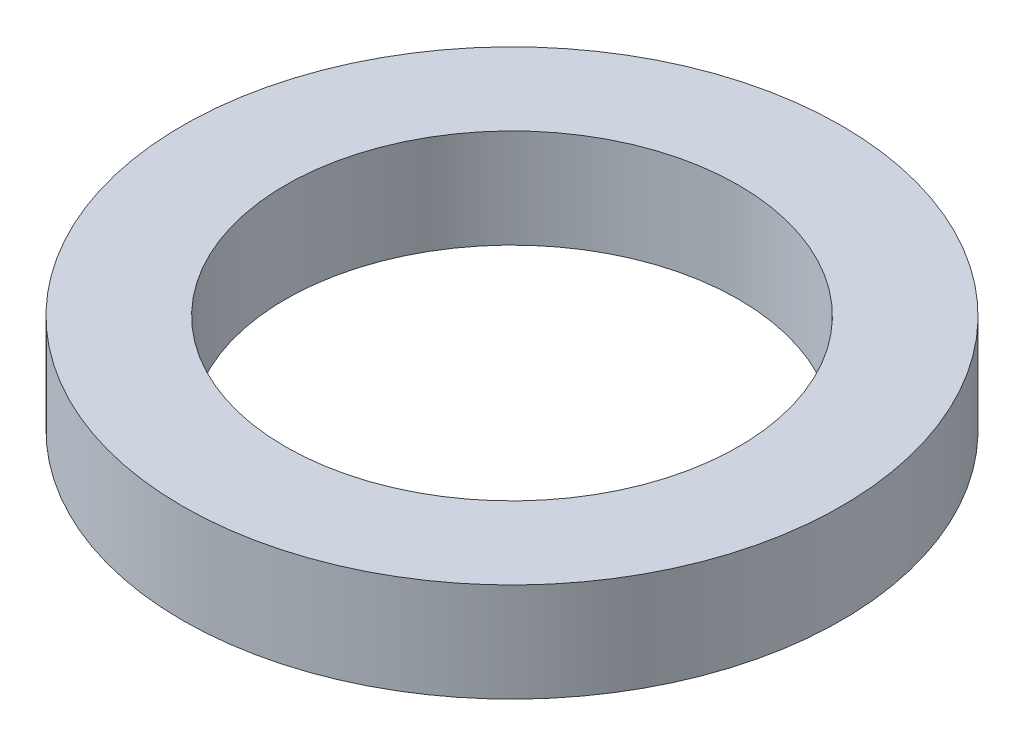
from build123d import *

# Parameters (mm, degrees)
SKETCH1_R           = 4
SKETCH1_R_2         = 2.75
BOSS_EXTRUDE1_DEPTH = 1.2


with BuildPart() as part:
    # Sketch1 → Boss-Extrude1 (new body)
    with BuildSketch(Plane(origin=(0, 0, 0), x_dir=(1, 0, 0), z_dir=(0, 1, 0))):
        Circle(SKETCH1_R)
        Circle(SKETCH1_R_2, mode=Mode.SUBTRACT)
    extrude(amount=BOSS_EXTRUDE1_DEPTH)


solid = part.part
